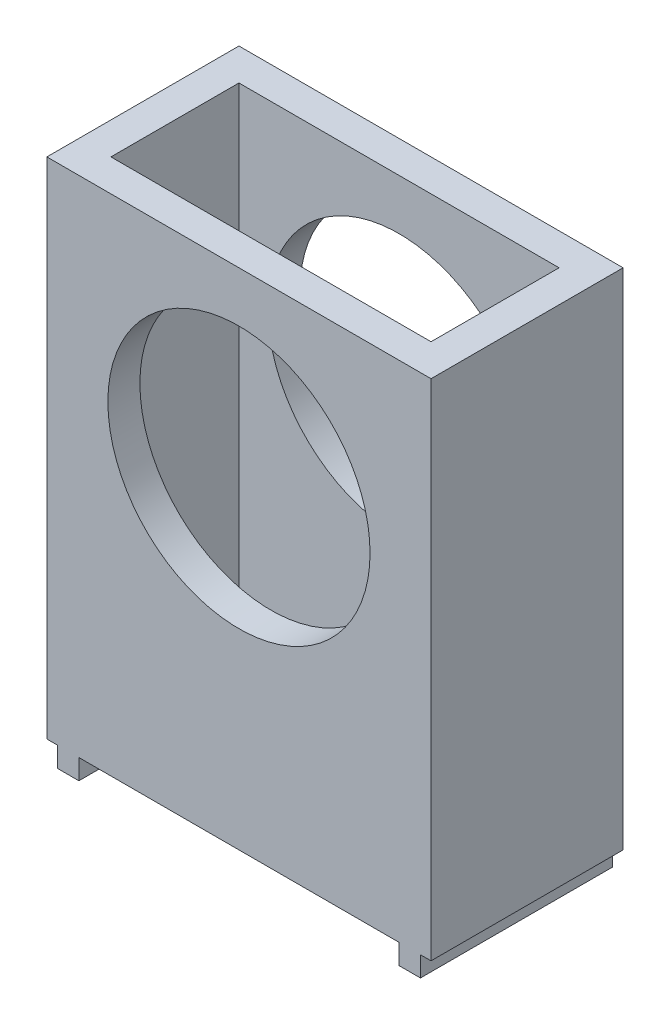
from build123d import *

# Parameters (mm, degrees)
SKETCH2_W                = 38.1
SKETCH2_H                = 19.05
SKETCH2_W_2              = 31.75
SKETCH2_H_2              = 12.7
BOSS_EXTRUDE1_DEPTH      = 18
BOSS_EXTRUDE1_DEPTH_BACK = 32
SKETCH3_R                = 13
CUT_EXTRUDE1_DEPTH       = 20.05
SKETCH5_W                = 2.125
SKETCH5_H                = 19.05
BOSS_EXTRUDE2_DEPTH      = 2


with BuildPart() as part:
    # Sketch2 → Boss-Extrude1 (new body, two sides)
    with BuildSketch(Plane(origin=(0, 0, 0), x_dir=(1, 0, 0), z_dir=(0, 1, 0))) as boss_extrude1_sk:
        Rectangle(SKETCH2_W, SKETCH2_H)
        Rectangle(SKETCH2_W_2, SKETCH2_H_2, mode=Mode.SUBTRACT)
    extrude(amount=BOSS_EXTRUDE1_DEPTH)
    extrude(boss_extrude1_sk.sketch, amount=-BOSS_EXTRUDE1_DEPTH_BACK)

    # Sketch3 → Cut-Extrude1 (cut, through all)
    with BuildSketch(Plane.XY.offset(9.525)):
        Circle(SKETCH3_R)
    extrude(amount=-CUT_EXTRUDE1_DEPTH, mode=Mode.SUBTRACT)

    # Sketch5 → Boss-Extrude2 (add)
    with BuildSketch(Plane.XZ.offset(32)):
        with Locations((-16.9375, 0)):
            Rectangle(SKETCH5_W, SKETCH5_H)
        with Locations((16.9375, 0)):
            Rectangle(SKETCH5_W, SKETCH5_H)
    extrude(amount=BOSS_EXTRUDE2_DEPTH)


solid = part.part
